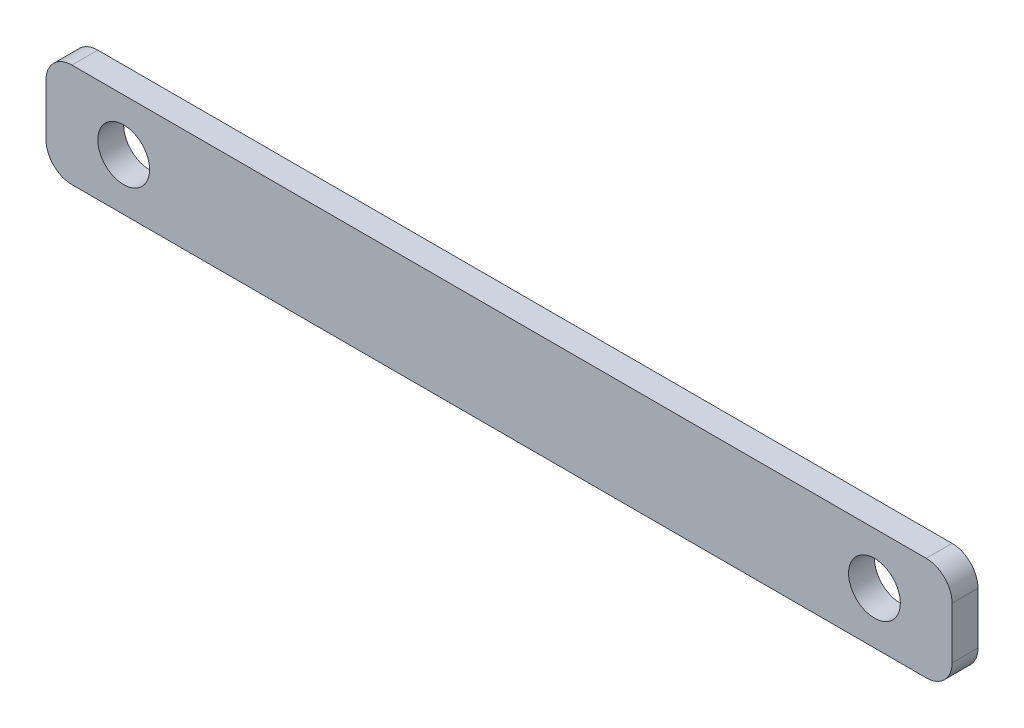
from build123d import *

# Parameters (mm, degrees)
SKETCH1_R           = 10
BOSS_EXTRUDE1_DEPTH = 5


with BuildPart() as part:
    # Sketch1 → Boss-Extrude1 (new body, symmetric)
    with BuildSketch(Plane.XY):
        with BuildLine():
            Line((-190, 151.994660309), (140, 151.994660309))
            ThreePointArc((140, 151.994660309), (147.071067812, 149.065728121), (150, 141.994660309))
            Line((150, 141.994660309), (150, 121.994660309))
            ThreePointArc((150, 121.994660309), (147.071067812, 114.923592497), (140, 111.994660309))
            Line((140, 111.994660309), (-190, 111.994660309))
            ThreePointArc((-190, 111.994660309), (-197.071067812, 114.923592497), (-200, 121.994660309))
            Line((-200, 121.994660309), (-200, 141.994660309))
            ThreePointArc((-200, 141.994660309), (-197.071067812, 149.065728121), (-190, 151.994660309))
        make_face()
        with Locations((-170, 131.994660309)):
            Circle(SKETCH1_R, mode=Mode.SUBTRACT)
        with Locations((120, 131.994660309)):
            Circle(SKETCH1_R, mode=Mode.SUBTRACT)
    extrude(amount=BOSS_EXTRUDE1_DEPTH, both=True)


solid = part.part
